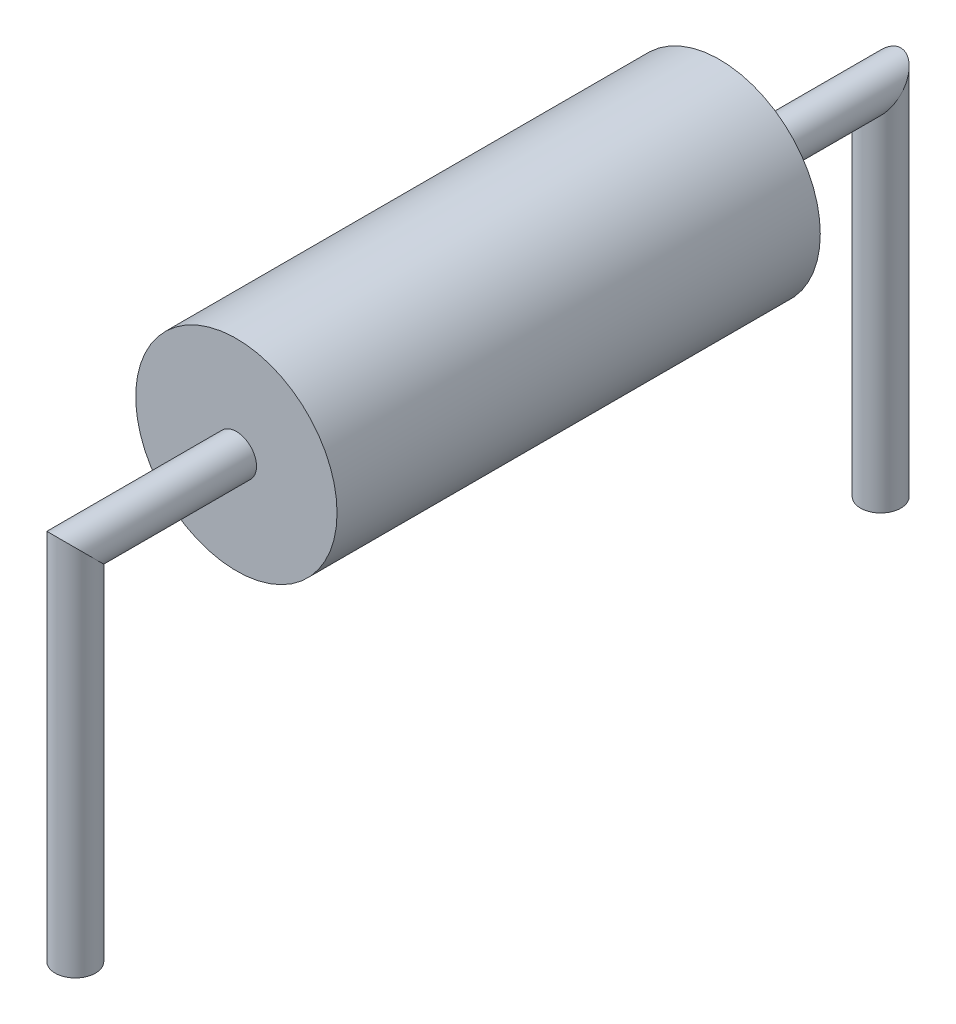
from build123d import *
from build123d.topology import SkipClean

# Parameters (mm, degrees)
SKETCH1_R                       = 1.25
BOSS_EXTRUDE1_DEPTH             = 3
BOSS_EXTRUDE2_DEPTH             = 2.25
BOSS_EXTRUDE2_DEPTH_BACK        = 8.25
SKETCH2_R                       = 0.25
BOSS_EXTRUDE3_REACH             = 7.948
SKETCH3_R                       = 0.25
BOSS_EXTRUDE3_DIRECTION_2_DEPTH = 3.2
CUT_EXTRUDE1_DEPTH              = 8.849522278


with BuildPart() as part:
    # Sketch1 → Boss-Extrude1 (new, symmetric)
    with BuildSketch(Plane.XY):
        with Locations((0, 1.25)):
            Circle(SKETCH1_R)
    extrude(amount=BOSS_EXTRUDE1_DEPTH, both=True)

    # Sketch2 → Boss-Extrude2 (add, two sides: drawn at the far end of the back side and taken through both)
    with BuildSketch(Plane.XY.offset(3).offset(-BOSS_EXTRUDE2_DEPTH_BACK)):
        with Locations((0, 1.25)):
            Circle(SKETCH2_R)
    extrude(amount=BOSS_EXTRUDE2_DEPTH + BOSS_EXTRUDE2_DEPTH_BACK)

    # Sketch3 → Boss-Extrude3 (add, up to next)
    with BuildSketch(Plane(origin=(0, 0, 0), x_dir=(1, 0, 0), z_dir=(0, 1, 0)), mode=Mode.PRIVATE) as boss_extrude3_sk1:
        with Locations((0, -5)):
            Circle(SKETCH3_R)
    boss_extrude3_tool1 = extrude(boss_extrude3_sk1.sketch, amount=BOSS_EXTRUDE3_REACH, mode=Mode.PRIVATE) - part.part
    # Sketch3 → Boss-Extrude3 (add, up to next)
    with BuildSketch(Plane(origin=(0, 0, 0), x_dir=(1, 0, 0), z_dir=(0, 1, 0)), mode=Mode.PRIVATE) as boss_extrude3_sk2:
        with Locations((0, 5)):
            Circle(SKETCH3_R)
    boss_extrude3_tool2 = extrude(boss_extrude3_sk2.sketch, amount=BOSS_EXTRUDE3_REACH, mode=Mode.PRIVATE) - part.part
    add(boss_extrude3_tool1.solids().sort_by_distance((0, 0, 5))[0])
    add(boss_extrude3_tool2.solids().sort_by_distance((0, 0, -5))[0])

    # Sketch3 → Boss-Extrude3 direction 2 (add)
    with SkipClean():  # the faces are left unmerged after this step: merging them gives an invalid solid
        with BuildSketch(Plane(origin=(0, 0, 0), x_dir=(1, 0, 0), z_dir=(0, 1, 0))):
            with Locations((0, -5)):
                Circle(SKETCH3_R)
            with Locations((0, 5)):
                Circle(SKETCH3_R)
        extrude(amount=-BOSS_EXTRUDE3_DIRECTION_2_DEPTH)

    # Sketch4 → Cut-Extrude1 (cut, through all)
    with BuildSketch(Plane(origin=(0, -3.2, 0), x_dir=(-1, 0, 0), z_dir=(0, -1, 0))):
        with BuildLine():
            Line((0.25, -5), (0.35, -5))
            Line((0.35, -5), (0.35, -5.35))
            Line((0.35, -5.35), (-0.35, -5.35))
            Line((-0.35, -5.35), (-0.35, -5))
            Line((-0.35, -5), (-0.25, -5))
            ThreePointArc((-0.25, -5), (0, -5.25), (0.25, -5))
        make_face()
        with BuildLine():
            Line((-0.25, 5), (-0.35, 5))
            Line((-0.35, 5), (-0.35, 5.35))
            Line((-0.35, 5.35), (0.35, 5.35))
            Line((0.35, 5.35), (0.35, 5))
            Line((0.35, 5), (0.25, 5))
            ThreePointArc((0.25, 5), (0, 5.25), (-0.25, 5))
        make_face()
    extrude(amount=-CUT_EXTRUDE1_DEPTH, mode=Mode.SUBTRACT)


solid = part.part
